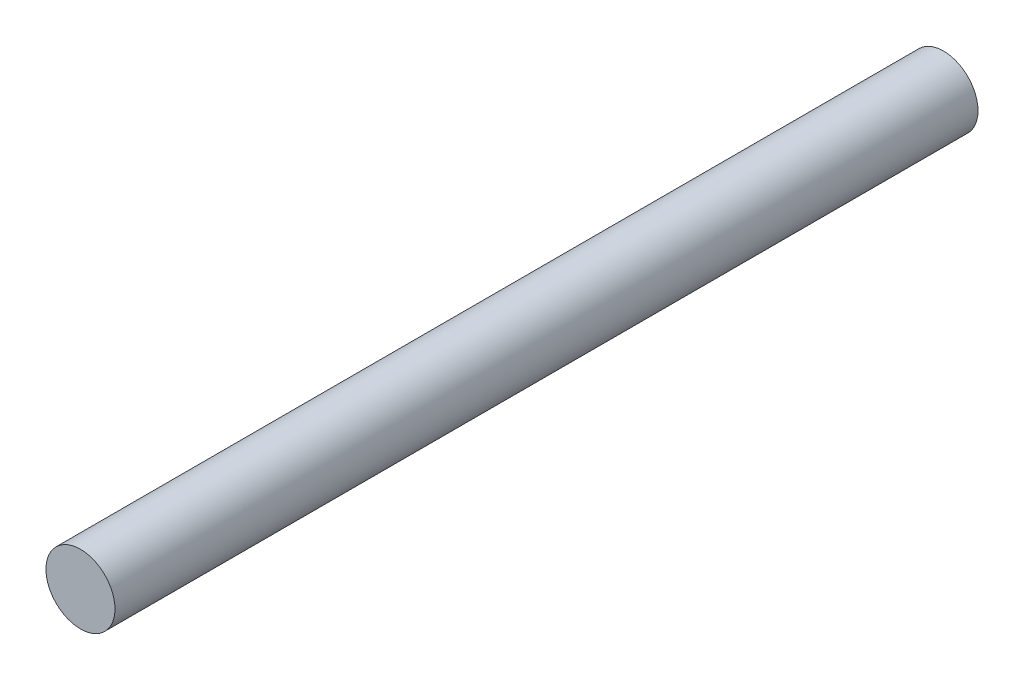
from build123d import *

# Parameters (mm, degrees)
ESQUISSE1_R        = 4
BOSS_EXTRU_1_DEPTH = 100


with BuildPart() as part:
    # Esquisse1 → Boss.-Extru.1 (new body)
    with BuildSketch(Plane.XY):
        Circle(ESQUISSE1_R)
    extrude(amount=BOSS_EXTRU_1_DEPTH)


solid = part.part
